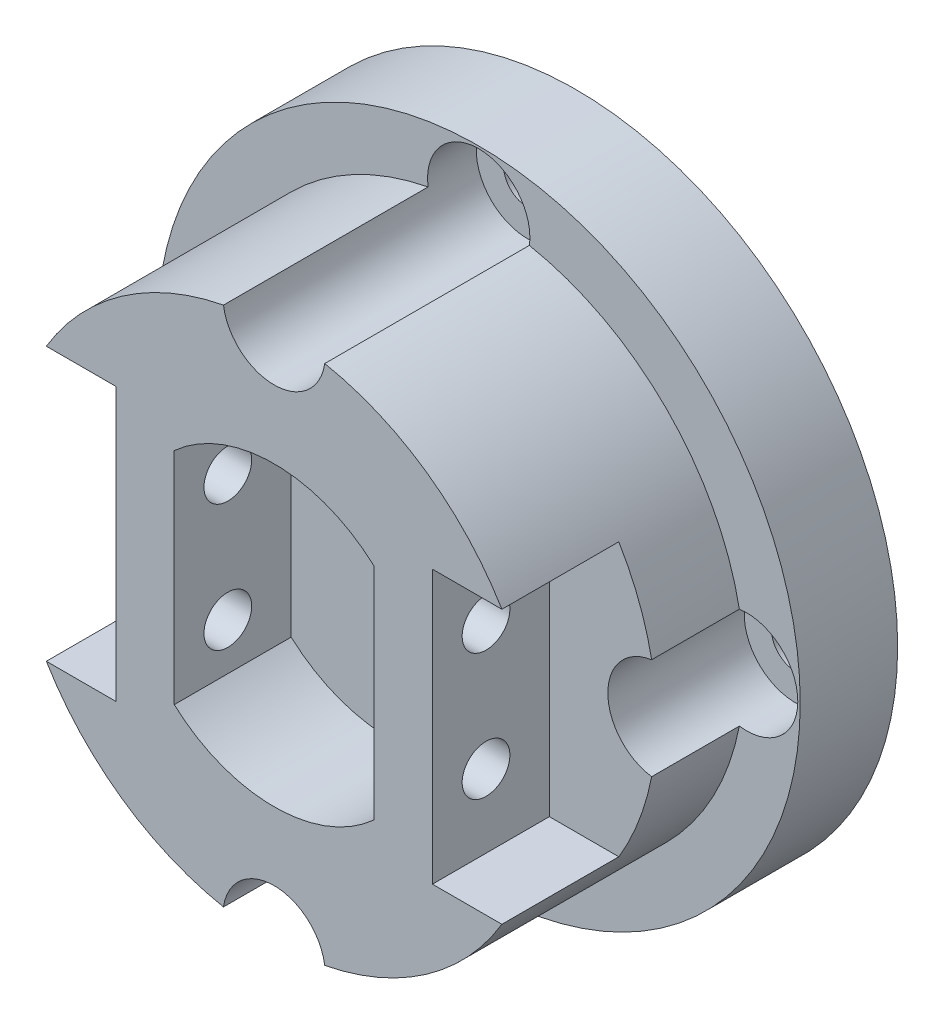
from build123d import *

# Parameters (mm, degrees)
SKETCH1_R           = 33
EXTRUDE1_DEPTH      = 10
SKETCH2_R           = 27.25
EXTRUDE2_DEPTH      = 21
EXTRUDE3_DEPTH      = 12
SKETCH4_R           = 2.45
EXTRUDE4_DEPTH      = 36
SKETCH5_R           = 2.45
EXTRUDE5_DEPTH      = 38
EXTRUDE5_DEPTH_BACK = 38
SKETCH6_W           = 19.894607887
SKETCH6_H           = 28
EXTRUDE6_DEPTH      = 12
SKETCH8_R           = 5.25
EXTRUDE7_DEPTH      = 26


with BuildPart() as part:
    # Sketch1 → Extrude1 (new body)
    with BuildSketch(Plane.XY):
        Circle(SKETCH1_R)
    extrude(amount=EXTRUDE1_DEPTH)

    # Sketch2 → Extrude2 (add)
    with BuildSketch(Plane.XY.offset(10)):
        Circle(SKETCH2_R)
    extrude(amount=EXTRUDE2_DEPTH)

    # Sketch3 → Extrude3 (cut)
    with BuildSketch(Plane.XY.offset(31)):
        with BuildLine():
            Line((-10.25, 11.291589791), (-10.25, -11.291589791))
            ThreePointArc((-10.25, -11.291589791), (0, -15.25), (10.25, -11.291589791))
            Line((10.25, -11.291589791), (10.25, 11.291589791))
            ThreePointArc((10.25, 11.291589791), (0, 15.25), (-10.25, 11.291589791))
        make_face()
    extrude(amount=-EXTRUDE3_DEPTH, mode=Mode.SUBTRACT)

    # Sketch4 → Extrude4 (cut)
    with BuildSketch(Plane(origin=(0, 0, 0), x_dir=(-1, 0, 0), z_dir=(0, 0, -1))):
        with Locations((0, 27.5)):
            Circle(SKETCH4_R)
        with Locations((-27.5, 0)):
            Circle(SKETCH4_R)
        with Locations((0, -27.5)):
            Circle(SKETCH4_R)
        with Locations((27.5, 0)):
            Circle(SKETCH4_R)
    extrude(amount=-EXTRUDE4_DEPTH, mode=Mode.SUBTRACT)

    # Sketch5 → Extrude5 (cut, two sides)
    with BuildSketch(Plane.ZY.offset(-10.25)) as extrude5_sk:
        with Locations((25.5, 6.5)):
            Circle(SKETCH5_R)
        with Locations((25.5, -6.5)):
            Circle(SKETCH5_R)
    extrude(amount=EXTRUDE5_DEPTH, mode=Mode.SUBTRACT)
    extrude(extrude5_sk.sketch, amount=-EXTRUDE5_DEPTH_BACK, mode=Mode.SUBTRACT)

    # Sketch6 → Extrude6 (cut)
    with BuildSketch(Plane.XY.offset(31)):
        with Locations((-26.197303943, 0)):
            Rectangle(SKETCH6_W, SKETCH6_H)
    extrude6 = extrude(amount=-EXTRUDE6_DEPTH, mode=Mode.SUBTRACT)

    # Mirror1: Extrude6 across plane
    add(extrude6.mirror(Plane(origin=(0, 0, 0), x_dir=(0, 0, 1), z_dir=(1, 0, 0))), mode=Mode.SUBTRACT)

    # Sketch8 → Extrude7 (cut)
    with BuildSketch(Plane.XY.offset(31)):
        with Locations((0, 27.5)):
            Circle(SKETCH8_R)
        with Locations((27.5, 0)):
            Circle(SKETCH8_R)
        with Locations((-27.5, 0)):
            Circle(SKETCH8_R)
        with Locations((0, -27.5)):
            Circle(SKETCH8_R)
    extrude(amount=-EXTRUDE7_DEPTH, mode=Mode.SUBTRACT)


solid = part.part
